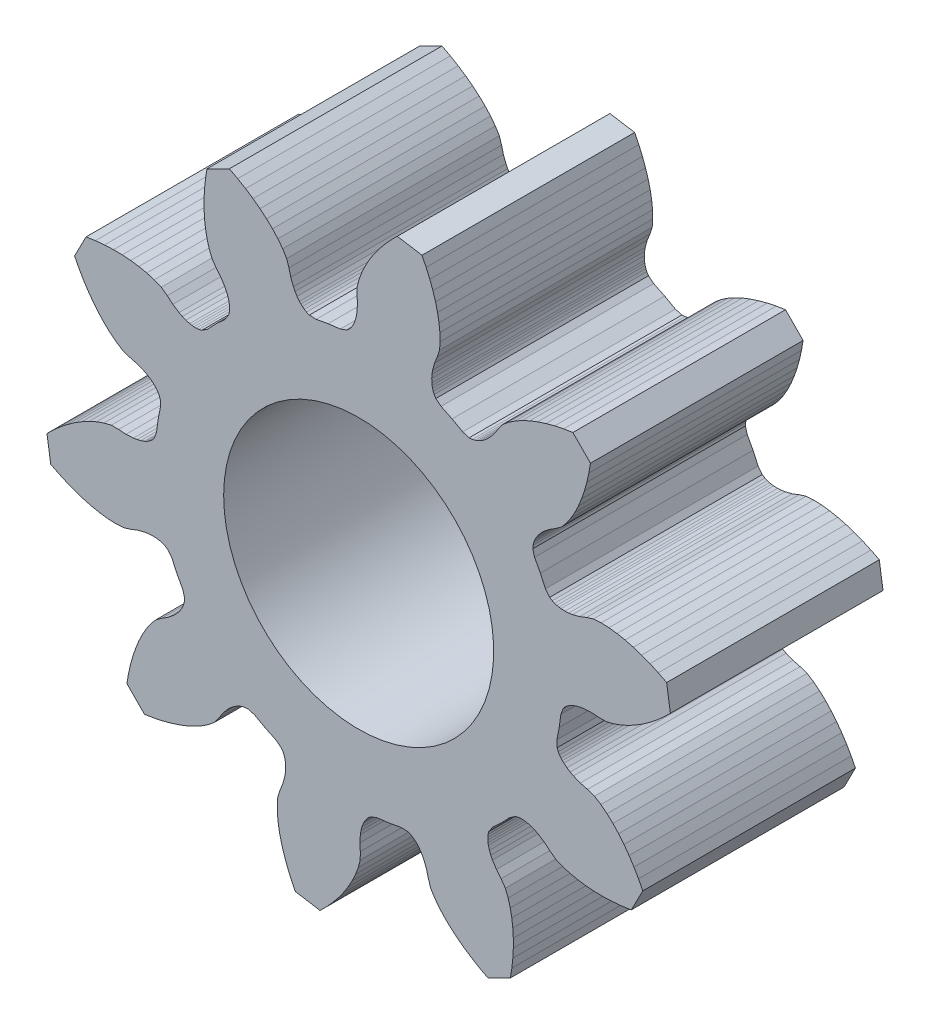
from build123d import *

# Parameters (mm, degrees)
EXTRUDE_GEAR_FACE_DEPTH = 10
SKETCH3_R               = 6.35
CUT_EXTRUDE1_DEPTH      = 11


with BuildPart() as part:
    # Sketch1 → Extrude gear face (new body)
    with BuildSketch(Plane.XY):
        Polygon((-8.785755588, -3.765027458), (-8.981475588, -3.515627458), (-9.104375588, -3.437067458), (-9.214815588, -3.388487458), (-9.318645588, -3.356197458), (-9.418135588, -3.334867458), (-9.514485588, -3.321697458), (-9.700295588, -3.313797458), (-9.879345588, -3.324657458), (-10.053295588, -3.350207458), (-10.389375588, -3.436367458), (-10.712795588, -3.560677458), (-11.043055588, -3.664357458), (-11.399975588, -3.686587458), (-11.767875588, -3.671647458), (-12.143785588, -3.625627458), (-12.525865588, -3.551357458), (-12.912635588, -3.450417458), (-13.302835588, -3.323837458), (-13.695295588, -3.172277458), (-14.088935588, -2.996237458), (-14.482675588, -2.796087458), (-14.659535588, -1.632117458), (-14.343025588, -1.324037458), (-14.019445588, -1.039017458), (-13.689715588, -0.777727458), (-13.354725588, -0.540947458), (-13.015395588, -0.329677458), (-12.672625588, -0.145267458), (-12.327345588, 0.010332542), (-11.980495588, 0.133882542), (-11.633085588, 0.218672542), (-11.286925588, 0.217772542), (-10.941175588, 0.195142542), (-10.594675588, 0.212702542), (-10.420995588, 0.239972542), (-10.246795588, 0.282782542), (-10.071725588, 0.345532542), (-9.983635588, 0.386722542), (-9.894965588, 0.436642542), (-9.805415588, 0.498312542), (-9.714385588, 0.577512542), (-9.620365588, 0.689032542), (-9.507565588, 0.985312542), (-9.431215588, 1.554652542), (-9.320805588, 2.118382542), (-9.332545588, 2.435192542), (-9.385805588, 2.570982542), (-9.446595588, 2.675212542), (-9.511615588, 2.762362542), (-9.579565588, 2.838102542), (-9.649775588, 2.905382542), (-9.795455588, 3.020992542), (-9.946695588, 3.117452542), (-10.102435588, 3.199022542), (-10.424975588, 3.326862542), (-10.759695588, 3.416392542), (-11.087825588, 3.526632542), (-11.389645588, 3.718442542), (-11.678495588, 3.946782542), (-11.955575588, 4.204962542), (-12.221015588, 4.489632542), (-12.474595588, 4.798622542), (-12.715865588, 5.130392542), (-12.944295588, 5.483682542), (-13.159275588, 5.857472542), (-13.360175588, 6.250842542), (-12.819095588, 7.296472542), (-12.381945588, 7.359662542), (-11.952645588, 7.400052542), (-11.532295588, 7.417632542), (-11.122115588, 7.412292542), (-10.723405588, 7.383762542), (-10.337705588, 7.331482542), (-9.966915588, 7.254412542), (-9.613685588, 7.150492542), (-9.282775588, 7.014882542), (-9.003265588, 6.810692542), (-8.736845588, 6.589162542), (-8.446195588, 6.399692542), (-8.289655588, 6.319672542), (-8.123565588, 6.251912542), (-7.945045588, 6.199772542), (-7.849565588, 6.181312542), (-7.748485588, 6.169592542), (-7.639795588, 6.166842542), (-7.519595588, 6.177412542), (-7.377995588, 6.212372542), (-7.112585588, 6.385762542), (-6.716155588, 6.801492542), (-6.295475588, 7.192662542), (-6.118765588, 7.455872542), (-6.082035588, 7.597022542), (-6.069955588, 7.717082542), (-6.071335588, 7.825802542), (-6.081785588, 7.927022542), (-6.099045588, 8.022722542), (-6.148945588, 8.201882542), (-6.214605588, 8.368812542), (-6.292655588, 8.526342542), (-6.478445588, 8.819352542), (-6.696615588, 9.088532542), (-6.897285588, 9.370582542), (-7.028725588, 9.703172542), (-7.128195588, 10.057682542), (-7.200595588, 10.429412542), (-7.248025588, 10.815742542), (-7.271545588, 11.214772542), (-7.271735588, 11.624992542), (-7.248875588, 12.045082542), (-7.203095588, 12.473852542), (-7.134405588, 12.910172542), (-6.082065588, 13.438062542), (-5.691255588, 13.232242542), (-5.320195588, 13.012582542), (-4.969795588, 12.779732542), (-4.641085588, 12.534302542), (-4.335305588, 12.276862542), (-4.053995588, 12.007862542), (-3.799315588, 11.727562542), (-3.574625588, 11.435872542), (-3.386625588, 11.131662542), (-3.280515588, 10.802172542), (-3.195195588, 10.466352542), (-3.071425588, 10.142232542), (-2.991815588, 9.985472542), (-2.897265588, 9.833042542), (-2.783495588, 9.685922542), (-2.717095588, 9.614872542), (-2.642215588, 9.545972542), (-2.555895588, 9.479852542), (-2.452435588, 9.417762542), (-2.317335588, 9.362802542), (-2.000695588, 9.347082542), (-1.435615588, 9.450402542), (-0.865355588, 9.519592542), (-0.567685588, 9.628662542), (-0.454995588, 9.721272542), (-0.374655588, 9.811292542), (-0.311875588, 9.900062542), (-0.260835588, 9.988102542), (-0.218545588, 10.075662542), (-0.153605588, 10.249942542), (-0.108605588, 10.423582542), (-0.079155588, 10.596902542), (-0.057245588, 10.943162542), (-0.075525588, 11.289172542), (-0.072075588, 11.635302542), (0.017074412, 11.981632542), (0.144974412, 12.326902542), (0.304904412, 12.670202542), (0.493604412, 13.010622542), (0.709124412, 13.347272542), (0.950094412, 13.679252542), (1.215504412, 14.005682542), (1.504574412, 14.325642542), (1.816604412, 14.638262542), (2.978254412, 14.446792542), (3.173444412, 14.050562542), (3.344524412, 13.654752542), (3.491134412, 13.260412542), (3.612814412, 12.868652542), (3.708874412, 12.480642542), (3.778344412, 12.097662542), (3.819634412, 11.721202542), (3.829954412, 11.353142542), (3.803234412, 10.996532542), (3.695414412, 10.667602542), (3.567044412, 10.345762542), (3.476674412, 10.010792542), (3.448934412, 9.837182542), (3.435824412, 9.658292542), (3.441394412, 9.472392542), (3.453354412, 9.375882542), (3.473434412, 9.276122542), (3.504404412, 9.171902542), (3.551604412, 9.060862542), (3.628614412, 8.936982542), (3.875534412, 8.738142542), (4.393414412, 8.489592542), (4.895434412, 8.210382542), (5.200374412, 8.123652542), (5.345974412, 8.132332542), (5.463884412, 8.157942542), (5.566854412, 8.192852542), (5.659894412, 8.234072542), (5.745574412, 8.280062542), (5.900544412, 8.382882542), (6.039014412, 8.496912542), (6.164724412, 8.619822542), (6.385974412, 8.887072542), (6.574564412, 9.177742542), (6.780804412, 9.455742542), (7.056494412, 9.683522542), (7.362904412, 9.887682542), (7.694074412, 10.071412542), (8.046834412, 10.235892542), (8.419074412, 10.381572542), (8.809154412, 10.508522542), (9.215754412, 10.616592542), (9.637674412, 10.705542542), (10.073864412, 10.775052542), (10.901124412, 9.937342542), (10.826134412, 9.502062542), (10.731884412, 9.081282542), (10.618714412, 8.676082542), (10.486874412, 8.287622542), (10.336534412, 7.917252542), (10.167624412, 7.566582542), (9.979744412, 7.237742542), (9.771754412, 6.933922542), (9.540534412, 6.661112542), (9.259954412, 6.458382542), (8.966944412, 6.273462542), (8.696934412, 6.055582542), (8.572454412, 5.931432542), (8.456694412, 5.794412542), (8.351934412, 5.640742542), (8.304874412, 5.555642542), (8.262484412, 5.463132542), (8.226284412, 5.360602542), (8.199204412, 5.243022542), (8.188684412, 5.097542542), (8.271574412, 4.791552542), (8.544454412, 4.286062542), (8.786484412, 3.765092542), (8.982204412, 3.515692542), (9.105104412, 3.437132542), (9.215544412, 3.388542542), (9.319364412, 3.356262542), (9.418864412, 3.334932542), (9.515214412, 3.321762542), (9.701024412, 3.313862542), (9.880074412, 3.324722542), (10.054014412, 3.350272542), (10.390094412, 3.436432542), (10.713524412, 3.560732542), (11.043784412, 3.664422542), (11.400704412, 3.686652542), (11.768604412, 3.671712542), (12.144514412, 3.625692542), (12.526594412, 3.551422542), (12.913364412, 3.450482542), (13.303564412, 3.323902542), (13.696024412, 3.172342542), (14.089654412, 2.996302542), (14.483404412, 2.796152542), (14.660264412, 1.632182542), (14.343754412, 1.324102542), (14.020174412, 1.039082542), (13.690444412, 0.777792542), (13.355454412, 0.541012542), (13.016124412, 0.329742542), (12.673354412, 0.145332542), (12.328074412, -0.010267458), (11.981224412, -0.133817458), (11.633804412, -0.218607458), (11.287654412, -0.217707458), (10.941904412, -0.195077458), (10.595404412, -0.212637458), (10.421724412, -0.239907458), (10.247524412, -0.282727458), (10.072454412, -0.345467458), (9.984364412, -0.386657458), (9.895694412, -0.436577458), (9.806144412, -0.498247458), (9.715114412, -0.577447458), (9.621094412, -0.688967458), (9.508294412, -0.985247458), (9.431944412, -1.554587458), (9.321524412, -2.118327458), (9.333274412, -2.435137458), (9.386524412, -2.570917458), (9.447314412, -2.675147458), (9.512344412, -2.762297458), (9.580294412, -2.838037458), (9.650504412, -2.905317458), (9.796184412, -3.020937458), (9.947424412, -3.117387458), (10.103164412, -3.198957458), (10.425704412, -3.326797458), (10.760424412, -3.416337458), (11.088554412, -3.526567458), (11.390374412, -3.718377458), (11.679224412, -3.946717458), (11.956304412, -4.204897458), (12.221744412, -4.489567458), (12.475324412, -4.798557458), (12.716594412, -5.130327458), (12.945024412, -5.483627458), (13.160004412, -5.857417458), (13.360904412, -6.250777458), (12.819824412, -7.296407458), (12.382674412, -7.359597458), (11.953364412, -7.399997458), (11.533024412, -7.417577458), (11.122844412, -7.412227458), (10.724134412, -7.383697458), (10.338434412, -7.331417458), (9.967634412, -7.254347458), (9.614404412, -7.150427458), (9.283504412, -7.014817458), (9.003994412, -6.810627458), (8.737574412, -6.589097458), (8.446924412, -6.399627458), (8.290384412, -6.319607458), (8.124294412, -6.251857458), (7.945774412, -6.199707458), (7.850294412, -6.181247458), (7.749214412, -6.169527458), (7.640524412, -6.166777458), (7.520324412, -6.177347458), (7.378714412, -6.212307458), (7.113314412, -6.385697458), (6.716884412, -6.801427458), (6.296204412, -7.192597458), (6.119494412, -7.455807458), (6.082764412, -7.596967458), (6.070674412, -7.717017458), (6.072064412, -7.825737458), (6.082514412, -7.926957458), (6.099774412, -8.022657458), (6.149674412, -8.201817458), (6.215324412, -8.368747458), (6.293384412, -8.526277458), (6.479174412, -8.819287458), (6.697344412, -9.088467458), (6.898014412, -9.370527458), (7.029444412, -9.703107458), (7.128924412, -10.057617458), (7.201324412, -10.429347458), (7.248754412, -10.815677458), (7.272274412, -11.214707458), (7.272464412, -11.624927458), (7.249604412, -12.045017458), (7.203824412, -12.473787458), (7.135134412, -12.910107458), (6.082784412, -13.437997458), (5.691984412, -13.232177458), (5.320924412, -13.012517458), (4.970524412, -12.779667458), (4.641814412, -12.534247458), (4.336034412, -12.276807458), (4.054724412, -12.007797458), (3.800044412, -11.727507458), (3.575354412, -11.435807458), (3.387354412, -11.131597458), (3.281244412, -10.802107458), (3.195924412, -10.466287458), (3.072154412, -10.142167458), (2.992544412, -9.985417458), (2.897994412, -9.832977458), (2.784224412, -9.685857458), (2.717824412, -9.614807458), (2.642944412, -9.545907458), (2.556624412, -9.479797458), (2.453164412, -9.417697458), (2.318054412, -9.362737458), (2.001424412, -9.347017458), (1.436344412, -9.450337458), (0.866084412, -9.519527458), (0.568414412, -9.628597458), (0.455724412, -9.721207458), (0.375384412, -9.811227458), (0.312594412, -9.899997458), (0.261564412, -9.988037458), (0.219264412, -10.075597458), (0.154334412, -10.249877458), (0.109334412, -10.423517458), (0.079874412, -10.596847458), (0.057964412, -10.943097458), (0.076244412, -11.289107458), (0.072804412, -11.635237458), (-0.016345588, -11.981567458), (-0.144245588, -12.326837458), (-0.304175588, -12.670137458), (-0.492885588, -13.010557458), (-0.708395588, -13.347207458), (-0.949365588, -13.679187458), (-1.214785588, -14.005617458), (-1.503845588, -14.325587458), (-1.815875588, -14.638207458), (-2.977525588, -14.446727458), (-3.172715588, -14.050497458), (-3.343795588, -13.654687458), (-3.490405588, -13.260347458), (-3.612085588, -12.868587458), (-3.708145588, -12.480577458), (-3.777615588, -12.097597458), (-3.818905588, -11.721137458), (-3.829225588, -11.353077458), (-3.802515588, -10.996467458), (-3.694685588, -10.667537458), (-3.566325588, -10.345697458), (-3.475945588, -10.010727458), (-3.448205588, -9.837117458), (-3.435095588, -9.658227458), (-3.440675588, -9.472327458), (-3.452625588, -9.375817458), (-3.472705588, -9.276067458), (-3.503685588, -9.171837458), (-3.550875588, -9.060797458), (-3.627885588, -8.936917458), (-3.874805588, -8.738077458), (-4.392685588, -8.489527458), (-4.894715588, -8.210317458), (-5.199645588, -8.123587458), (-5.345245588, -8.132277458), (-5.463155588, -8.157877458), (-5.566125588, -8.192787458), (-5.659165588, -8.234017458), (-5.744845588, -8.279997458), (-5.899815588, -8.382817458), (-6.038285588, -8.496847458), (-6.163995588, -8.619757458), (-6.385245588, -8.887007458), (-6.573835588, -9.177677458), (-6.780075588, -9.455677458), (-7.055765588, -9.683457458), (-7.362185588, -9.887617458), (-7.693345588, -10.071347458), (-8.046115588, -10.235837458), (-8.418345588, -10.381517458), (-8.808425588, -10.508457458), (-9.215025588, -10.616527458), (-9.636955588, -10.705487458), (-10.073145588, -10.774987458), (-10.900395588, -9.937277458), (-10.825405588, -9.501997458), (-10.731165588, -9.081217458), (-10.617985588, -8.676017458), (-10.486155588, -8.287557458), (-10.335805588, -7.917187458), (-10.166895588, -7.566517458), (-9.979015588, -7.237687458), (-9.771035588, -6.933857458), (-9.539805588, -6.661047458), (-9.259225588, -6.458317458), (-8.966215588, -6.273397458), (-8.696205588, -6.055527458), (-8.571725588, -5.931367458), (-8.455965588, -5.794347458), (-8.351205588, -5.640677458), (-8.304145588, -5.555577458), (-8.261755588, -5.463067458), (-8.225555588, -5.360537458), (-8.198475588, -5.242957458), (-8.187955588, -5.097487458), (-8.270845588, -4.791487458), (-8.543725588, -4.285997458), align=None)
    extrude(amount=EXTRUDE_GEAR_FACE_DEPTH)

    # Sketch3 → Cut-Extrude1 (cut, through all)
    with BuildSketch(Plane(origin=(0, 0, 0), x_dir=(-1, 0, 0), z_dir=(0, 0, -1))):
        Circle(SKETCH3_R)
    extrude(amount=-CUT_EXTRUDE1_DEPTH, mode=Mode.SUBTRACT)


solid = part.part
